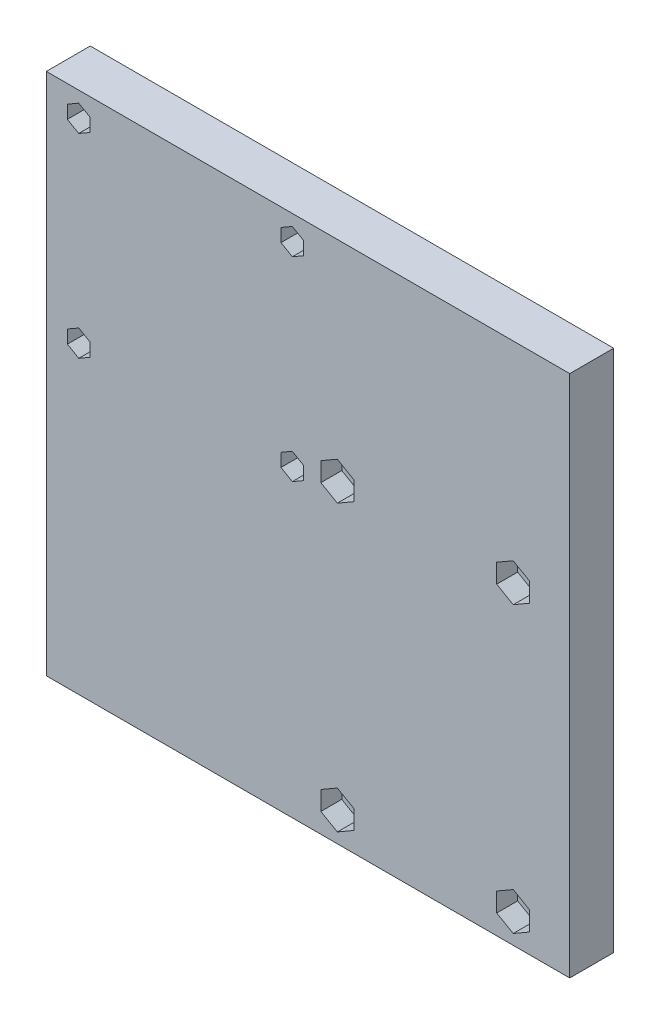
from build123d import *

# Parameters (mm, degrees)
SKETCH2_W           = 125
SKETCH2_H           = 125
SKETCH2_R           = 1.5
SKETCH2_R_2         = 2.5
BOSS_EXTRUDE1_DEPTH = 10.5
CUT_EXTRUDE1_DEPTH  = 5


with BuildPart() as part:
    # Sketch2 → Boss-Extrude1 (new body)
    with BuildSketch(Plane.XY):
        with Locations((29.251653193, -12.17)):
            Rectangle(SKETCH2_W, SKETCH2_H)
        with Locations((-25.5, -2)):
            Circle(SKETCH2_R, mode=Mode.SUBTRACT)
        with Locations((25.5, -2)):
            Circle(SKETCH2_R, mode=Mode.SUBTRACT)
        with Locations((78.251653193, 0.33)):
            Circle(SKETCH2_R_2, mode=Mode.SUBTRACT)
        with Locations((36.251653193, 0.33)):
            Circle(SKETCH2_R_2, mode=Mode.SUBTRACT)
        with Locations((36.251653193, -67.67)):
            Circle(SKETCH2_R_2, mode=Mode.SUBTRACT)
        with Locations((78.251653193, -67.67)):
            Circle(SKETCH2_R_2, mode=Mode.SUBTRACT)
        with Locations((25.5, 44.5)):
            Circle(SKETCH2_R, mode=Mode.SUBTRACT)
        with Locations((-25.5, 44.5)):
            Circle(SKETCH2_R, mode=Mode.SUBTRACT)
    extrude(amount=BOSS_EXTRUDE1_DEPTH)

    # Sketch3 → Cut-Extrude1 (cut)
    with BuildSketch(Plane.XY.offset(10.5)):
        Polygon((74.316653193, -69.941873309), (78.251653193, -72.213746619), (82.186653193, -69.941873309), (82.186653193, -65.398126691), (78.251653193, -63.126253381), (74.316653193, -65.398126691), align=None)
        Polygon((36.251653193, -72.213746619), (40.186653193, -69.941873309), (40.186653193, -65.398126691), (36.251653193, -63.126253381), (32.316653193, -65.398126691), (32.316653193, -69.941873309), align=None)
        Polygon((36.251653193, -4.213746619), (40.186653193, -1.941873309), (40.186653193, 2.601873309), (36.251653193, 4.873746619), (32.316653193, 2.601873309), (32.316653193, -1.941873309), align=None)
        Polygon((78.251653193, -4.213746619), (82.186653193, -1.941873309), (82.186653193, 2.601873309), (78.251653193, 4.873746619), (74.316653193, 2.601873309), (74.316653193, -1.941873309), align=None)
        Polygon((22.785, -3.567505981), (25.5, -5.135011962), (28.215, -3.567505981), (28.215, -0.432494019), (25.5, 1.135011962), (22.785, -0.432494019), align=None)
        Polygon((-28.215, -3.567505981), (-25.5, -5.135011962), (-22.785, -3.567505981), (-22.785, -0.432494019), (-25.5, 1.135011962), (-28.215, -0.432494019), align=None)
        Polygon((22.785, 42.932494019), (25.5, 41.364988038), (28.215, 42.932494019), (28.215, 46.067505981), (25.5, 47.635011962), (22.785, 46.067505981), align=None)
        Polygon((-28.215, 42.932494019), (-25.5, 41.364988038), (-22.785, 42.932494019), (-22.785, 46.067505981), (-25.5, 47.635011962), (-28.215, 46.067505981), align=None)
    extrude(amount=-CUT_EXTRUDE1_DEPTH, mode=Mode.SUBTRACT)


solid = part.part
